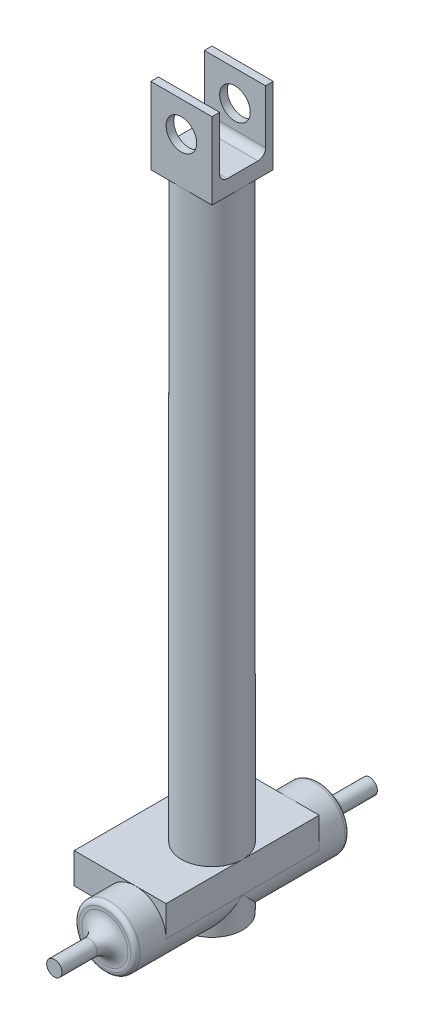
from build123d import *

# Parameters (mm, degrees)
SKETCH2_R           = 20
SKETCH2_R_2         = 10
EXTRUDE1_DEPTH      = 420.09
SKETCH3_R           = 20
SKETCH3_R_2         = 15
EXTRUDE2_DEPTH      = 60
EXTRUDE2_DEPTH_BACK = 60
SKETCH4_R           = 20
EXTRUDE3_DEPTH      = 10
SKETCH5_R           = 20
EXTRUDE4_DEPTH      = 10
SKETCH6_R           = 5
EXTRUDE5_DEPTH      = 33
SKETCH7_R           = 5
EXTRUDE6_DEPTH      = 33
SKETCH8_W           = 40
SKETCH8_H           = 40
EXTRUDE7_DEPTH      = 10
SKETCH9_W           = 40
SKETCH9_H           = 5
EXTRUDE8_DEPTH      = 40
SKETCH10_R          = 10
CUT_EXTRUDE1_DEPTH  = 124
FILLET1_R           = 3
FILLET2_R           = 3
SKETCH11_W          = 60
SKETCH11_H          = 100
EXTRUDE9_DEPTH      = 20
FILLET3_R           = 10
FILLET4_R           = 5


with BuildPart() as part:
    # Sketch2 → Extrude1 (new body)
    with BuildSketch(Plane(origin=(0, 0, 0), x_dir=(1, 0, 0), z_dir=(0, 1, 0))):
        with Locations(Location((0, 0, 0), (0, 0, 270))):  # turned: the seam where the file's is
            Circle(SKETCH2_R)
        with Locations(Location((0, 0, 0), (0, 0, 270))):  # turned: the seam where the file's is
            Circle(SKETCH2_R_2, mode=Mode.SUBTRACT)
    extrude(amount=EXTRUDE1_DEPTH)

    # Sketch3 → Extrude2 (add, two sides)
    with BuildSketch(Plane.XY) as extrude2_sk:
        with Locations((0, 20)):
            Circle(SKETCH3_R)
        with Locations(Location((0, 20, 0), (0, 0, 180))):  # turned: the seam where the file's is
            Circle(SKETCH3_R_2, mode=Mode.SUBTRACT)
    extrude(amount=EXTRUDE2_DEPTH)
    extrude(extrude2_sk.sketch, amount=-EXTRUDE2_DEPTH_BACK)

    # Sketch4 → Extrude3 (add)
    with BuildSketch(Plane.XY.offset(60)):
        with Locations((0, 20)):
            Circle(SKETCH4_R)
    extrude(amount=EXTRUDE3_DEPTH)

    # Sketch5 → Extrude4 (add)
    with BuildSketch(Plane(origin=(0, 0, -60), x_dir=(-1, 0, 0), z_dir=(0, 0, -1))):
        with Locations(Location((0, 20, 0), (0, 0, 180))):  # turned: the seam where the file's is
            Circle(SKETCH5_R)
    extrude(amount=EXTRUDE4_DEPTH)

    # Sketch6 → Extrude5 (add)
    with BuildSketch(Plane(origin=(0, 0, -70), x_dir=(-1, 0, 0), z_dir=(0, 0, -1))):
        with Locations((0, 20)):
            Circle(SKETCH6_R)
    extrude(amount=EXTRUDE5_DEPTH)

    # Sketch7 → Extrude6 (add)
    with BuildSketch(Plane.XY.offset(70)):
        with Locations(Location((0, 20, 0), (0, 0, 180))):  # turned: the seam where the file's is
            Circle(SKETCH7_R)
    extrude(amount=EXTRUDE6_DEPTH)

    # Sketch8 → Extrude7 (add)
    with BuildSketch(Plane(origin=(0, 420.09, 0), x_dir=(-1, 0, 0), z_dir=(0, 1, 0))):
        Rectangle(SKETCH8_W, SKETCH8_H)
    extrude(amount=EXTRUDE7_DEPTH)

    # Sketch9 → Extrude8 (add)
    with BuildSketch(Plane(origin=(0, 430.09, 0), x_dir=(-1, 0, 0), z_dir=(0, 1, 0))):
        with Locations((0, 17.5)):
            Rectangle(SKETCH9_W, SKETCH9_H)
        with Locations((0, -17.5)):
            Rectangle(SKETCH9_W, SKETCH9_H)
    extrude(amount=EXTRUDE8_DEPTH)

    # Sketch10 → Cut-Extrude1 (cut, through all)
    with BuildSketch(Plane(origin=(0, 0, -20), x_dir=(-1, 0, 0), z_dir=(0, 0, -1))):
        with Locations((0, 450.09)):
            Circle(SKETCH10_R)
    extrude(amount=-CUT_EXTRUDE1_DEPTH, mode=Mode.SUBTRACT)

    # Fillet1
    fillet1_edges = [part.edges().sort_by_distance(p)[0] for p in [
        (-20, 20, 70),
    ]]
    fillet(fillet1_edges, radius=FILLET1_R)

    # Fillet2
    fillet2_edges = [part.edges().sort_by_distance(p)[0] for p in [
        (-20, 20, -70),
    ]]
    fillet(fillet2_edges, radius=FILLET2_R)

    # Sketch11 → Extrude9 (add)
    with BuildSketch(Plane.XZ.offset(-40)):
        with Locations((-10, 0)):
            Rectangle(SKETCH11_W, SKETCH11_H)
    extrude(amount=EXTRUDE9_DEPTH)

    # Fillet3
    fillet3_edges = [part.edges().sort_by_distance(p)[0] for p in [
        (5, 20, -70),
        (5, 20, 70),
    ]]
    fillet(fillet3_edges, radius=FILLET3_R)

    # Fillet4
    fillet4_edges = [part.edges().sort_by_distance(p)[0] for p in [
        (0, 430.09, -15),
        (0, 430.09, 15),
    ]]
    fillet(fillet4_edges, radius=FILLET4_R)


solid = part.part
